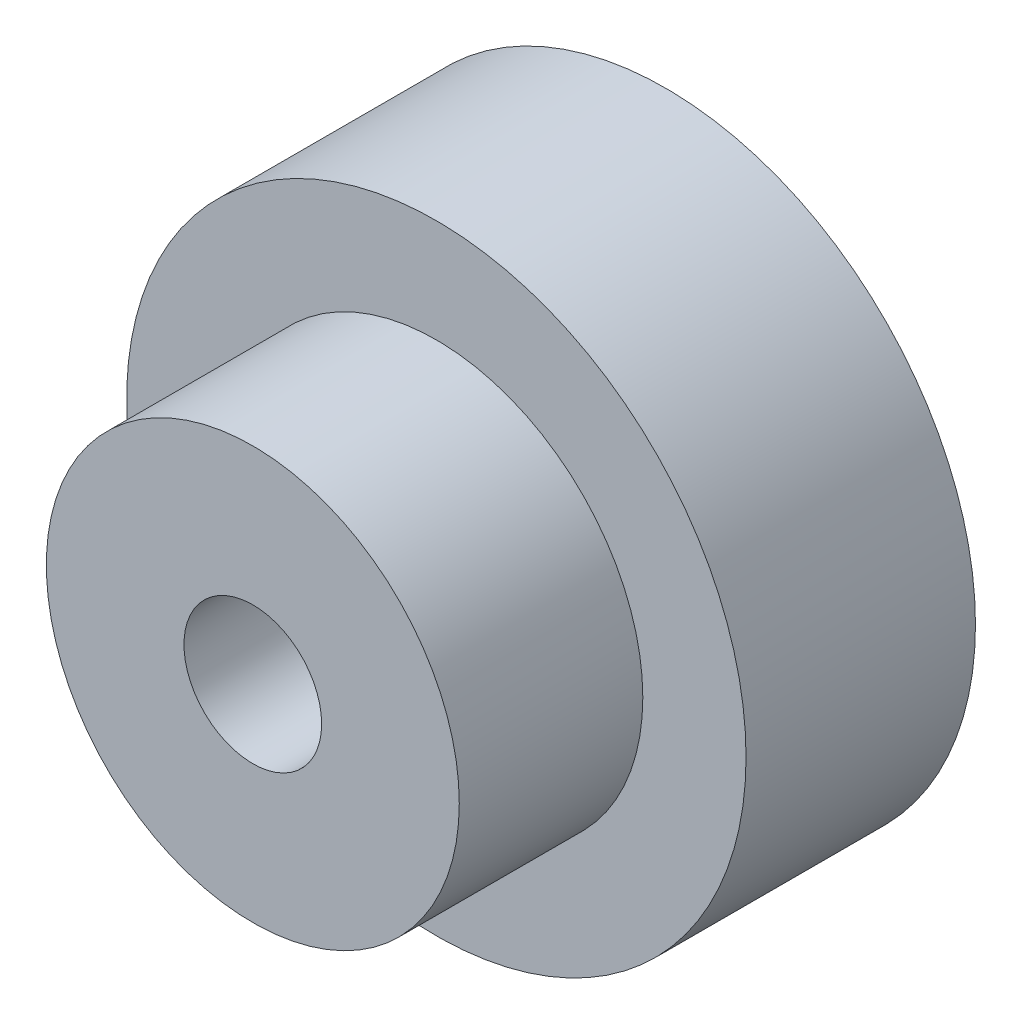
from build123d import *

# Parameters (mm, degrees)
SKETCH_1_R          = 13.5
EXTRUDE_1_DEPTH     = 10
SKETCH_2_R          = 9
EXTRUDE_2_DEPTH     = 8
SKETCH_3_R          = 3
CUT_EXTRUDE_1_DEPTH = 19


with BuildPart() as part:
    # 草图1 → 凸台-拉伸1 (new body)
    with BuildSketch(Plane.XY):
        Circle(SKETCH_1_R)
    extrude(amount=EXTRUDE_1_DEPTH)

    # 草图2 → 凸台-拉伸2 (add)
    with BuildSketch(Plane.XY.offset(10)):
        Circle(SKETCH_2_R)
    extrude(amount=EXTRUDE_2_DEPTH)

    # 草图3 → 切除-拉伸1 (cut, through all)
    with BuildSketch(Plane.XY.offset(18)):
        Circle(SKETCH_3_R)
    extrude(amount=-CUT_EXTRUDE_1_DEPTH, mode=Mode.SUBTRACT)


solid = part.part
